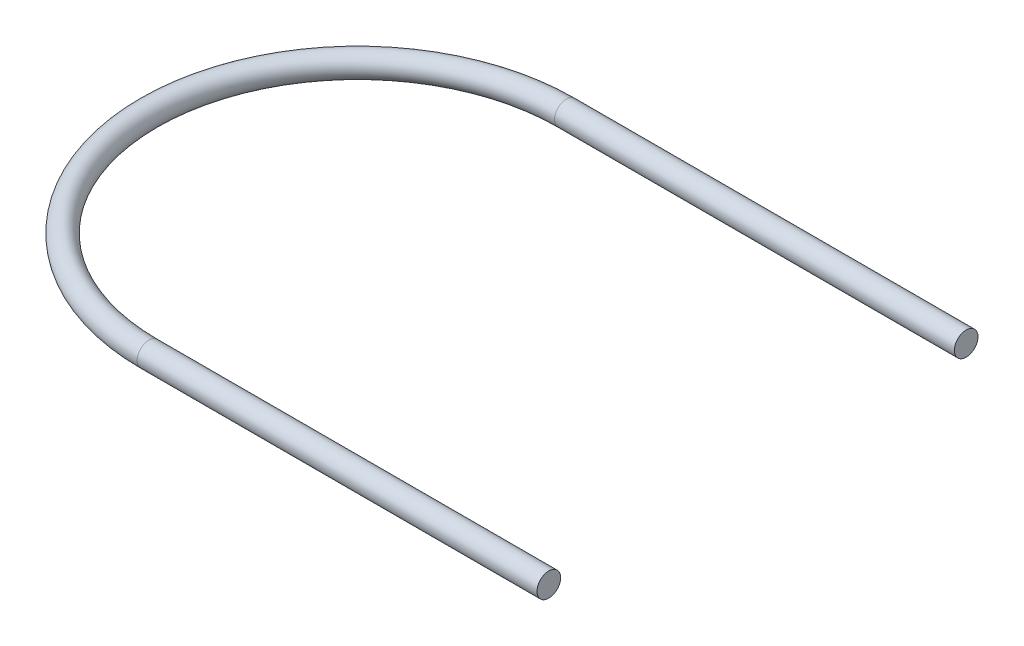
from build123d import *

# Parameters (mm, degrees)
SKETCH2_R = 0.4445


with BuildPart() as part:
    # Sweep1: sweep along a path in Sketch1
    with BuildLine(Plane(origin=(0, 0, 0), x_dir=(1, 0, 0), z_dir=(0, 1, 0))) as sweep1_path:
        Line((15.040898697, -7.85), (0, -7.85))
        ThreePointArc((0, -7.85), (-7.85, 0), (0, 7.85))
        Line((0, 7.85), (15.040898697, 7.85))
    # Sketch2 → Sweep1 (sweep)
    with BuildSketch(Plane(origin=(15.040898697, 0, 0), x_dir=(0, 0, -1), z_dir=(1, 0, 0))):
        with Locations((-7.85, 0)):
            Circle(SKETCH2_R)
    sweep(path=sweep1_path.line)


solid = part.part
